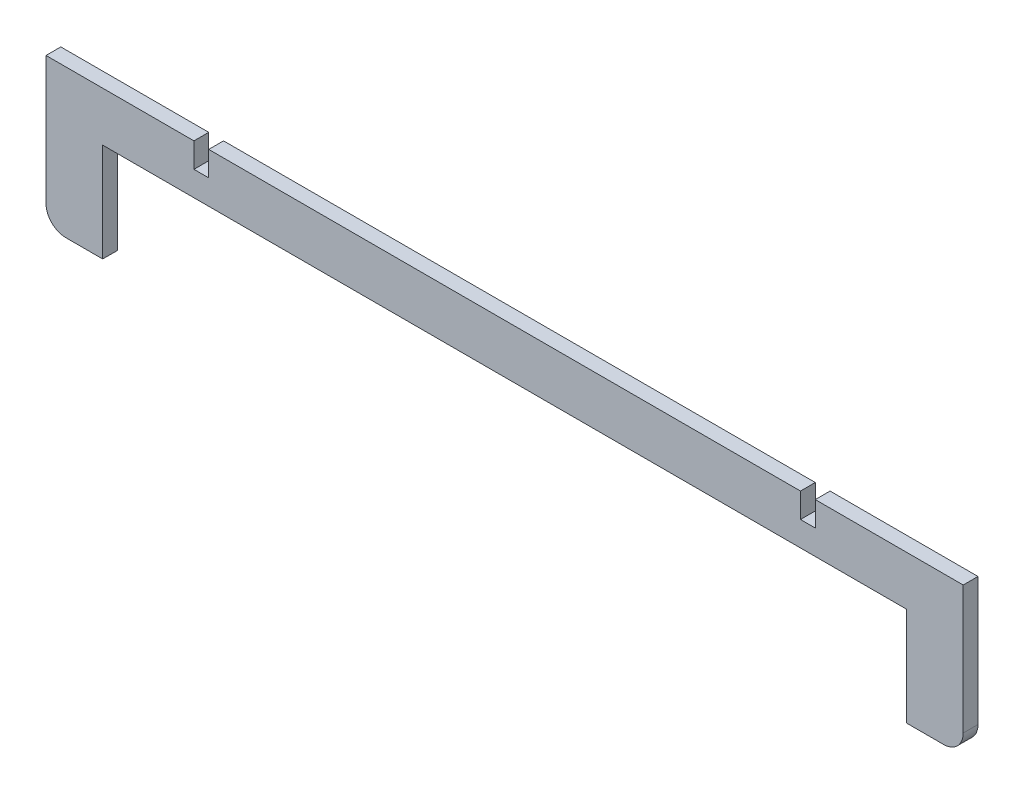
from build123d import *

# Parameters (mm, degrees)
BOSS_EXTRUDE1_DEPTH = 3
SKETCH2_W           = 163
SKETCH2_H           = 40
CUT_EXTRUDE1_DEPTH  = 3
FILLET1_R           = 4


with BuildPart() as part:
    # Sketch1 → Boss-Extrude1 (new body)
    with BuildSketch(Plane.XY):
        Polygon((-93, 15), (-63, 15), (-63, 10), (-60, 10), (-60, 15), (60, 15), (60, 10), (63, 10), (63, 15), (93, 15), (93, -15), (-93, -15), align=None)
    extrude(amount=BOSS_EXTRUDE1_DEPTH)

    # Sketch2 → Cut-Extrude1 (cut)
    with BuildSketch(Plane.XY.offset(3)):
        with Locations((0, -15)):
            Rectangle(SKETCH2_W, SKETCH2_H)
    extrude(amount=-CUT_EXTRUDE1_DEPTH, mode=Mode.SUBTRACT)

    # Fillet1
    fillet1_edges = [part.edges().sort_by_distance(p)[0] for p in [
        (93, -15, 1.5),
        (-93, -15, 1.5),
    ]]
    fillet(fillet1_edges, radius=FILLET1_R)


solid = part.part
